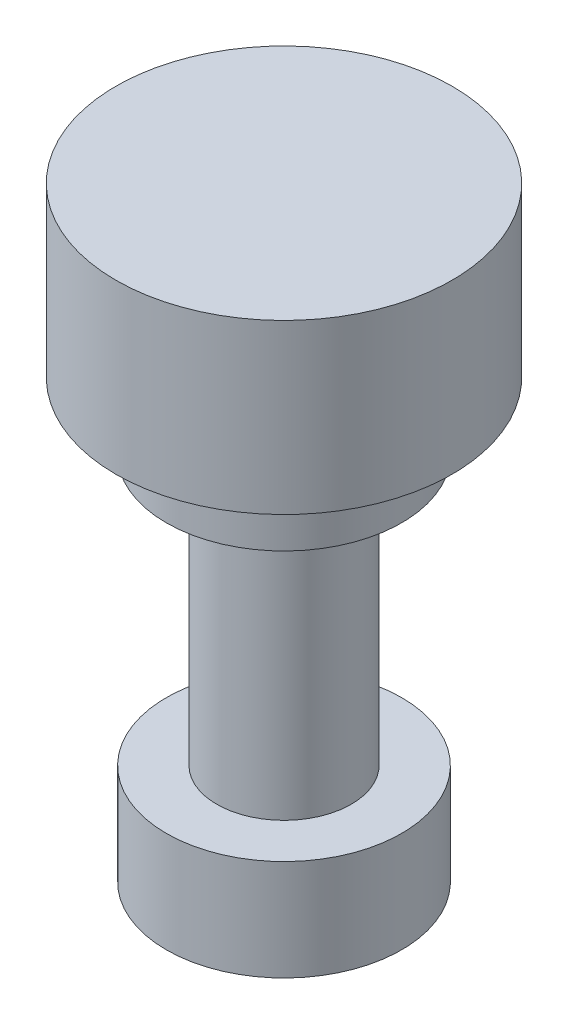
from build123d import *

# Parameters (mm, degrees)
SKETCH1_R           = 250
BOSS_EXTRUDE1_DEPTH = 125
SKETCH2_R           = 175
BOSS_EXTRUDE2_DEPTH = 100
SKETCH3_R           = 100
BOSS_EXTRUDE3_DEPTH = 400
SKETCH4_R           = 175
BOSS_EXTRUDE4_DEPTH = 150


with BuildPart() as part:
    # Sketch1 → Boss-Extrude1 (new body, symmetric)
    with BuildSketch(Plane(origin=(0, 0, 0), x_dir=(1, 0, 0), z_dir=(0, 1, 0))):
        Circle(SKETCH1_R)
    extrude(amount=BOSS_EXTRUDE1_DEPTH, both=True)

    # Sketch2 → Boss-Extrude2 (add)
    with BuildSketch(Plane.XZ.offset(125)):
        Circle(SKETCH2_R)
    extrude(amount=BOSS_EXTRUDE2_DEPTH)

    # Sketch3 → Boss-Extrude3 (add)
    with BuildSketch(Plane.XZ.offset(225)):
        Circle(SKETCH3_R)
    extrude(amount=BOSS_EXTRUDE3_DEPTH)

    # Sketch4 → Boss-Extrude4 (add)
    with BuildSketch(Plane.XZ.offset(625)):
        Circle(SKETCH4_R)
    extrude(amount=BOSS_EXTRUDE4_DEPTH)


solid = part.part
